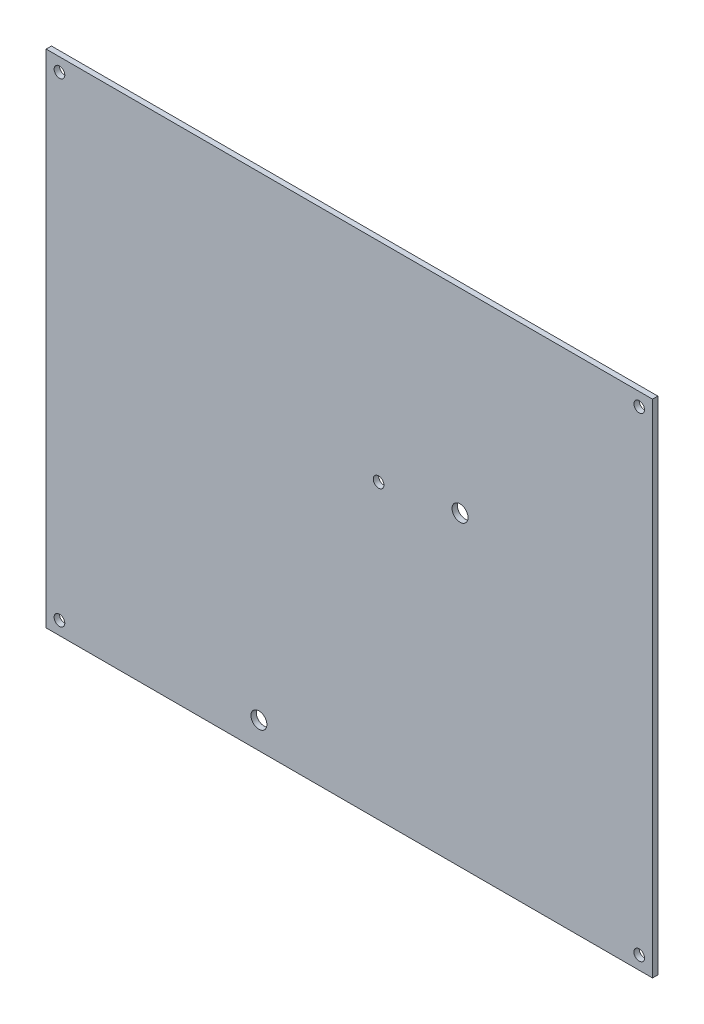
from build123d import *

# Parameters (mm, degrees)
SKETCH1_W           = 114
SKETCH1_H           = 110
BOSS_EXTRUDE1_DEPTH = 1
SKETCH2_R           = 1
CUT_EXTRUDE1_DEPTH  = 2
SKETCH3_R           = 1
CUT_EXTRUDE2_DEPTH  = 10
SKETCH4_W           = 15.73492188
SKETCH4_H           = 20.720243664
BOSS_EXTRUDE2_DEPTH = 1
SKETCH6_R           = 1
CUT_EXTRUDE3_DEPTH  = 10
SKETCH7_R           = 1.5
CUT_EXTRUDE4_DEPTH  = 10
SKETCH8_R           = 1.5
CUT_EXTRUDE5_DEPTH  = 10
SKETCH9_R           = 1
CUT_EXTRUDE6_DEPTH  = 2
SKETCH10_R          = 1
CUT_EXTRUDE7_DEPTH  = 2
SKETCH11_W          = 114
SKETCH11_H          = 15.75
CUT_EXTRUDE8_DEPTH  = 2


with BuildPart() as part:
    # Sketch1 → Boss-Extrude1 (new body)
    with BuildSketch(Plane.XY):
        with Locations((-26.754516262, 8.399305556)):
            Rectangle(SKETCH1_W, SKETCH1_H)
    extrude(amount=BOSS_EXTRUDE1_DEPTH)

    # Sketch2 → Cut-Extrude1 (cut, through all)
    with BuildSketch(Plane.XY.offset(1)):
        with Locations((-81.254516262, 60.899305556)):
            Circle(SKETCH2_R)
        with Locations((27.745483738, 60.899305556)):
            Circle(SKETCH2_R)
        with Locations((27.745483738, -44.100694444)):
            Circle(SKETCH2_R)
        with Locations((-81.254516262, -44.100694444)):
            Circle(SKETCH2_R)
    extrude(amount=-CUT_EXTRUDE1_DEPTH, mode=Mode.SUBTRACT)

    # Sketch3 → Cut-Extrude2 (cut)
    with BuildSketch(Plane(origin=(0, 0, 0), x_dir=(-1, 0, 0), z_dir=(0, 0, -1))):
        with Locations((28.754516262, 11.899305556)):
            Circle(SKETCH3_R)
    extrude(amount=-CUT_EXTRUDE2_DEPTH, mode=Mode.SUBTRACT)

    # Sketch4 → Boss-Extrude2 (add, through all)
    with BuildSketch(Plane.XY.offset(1)):
        with Locations((-27.299785832, 6.529809887)):
            Rectangle(SKETCH4_W, SKETCH4_H)
    extrude(amount=-BOSS_EXTRUDE2_DEPTH)

    # Sketch6 → Cut-Extrude3 (cut)
    with BuildSketch(Plane.XY.offset(1)):
        with Locations((-21.254516262, 8.399305556)):
            Circle(SKETCH6_R)
    extrude(amount=-CUT_EXTRUDE3_DEPTH, mode=Mode.SUBTRACT)

    # Sketch7 → Cut-Extrude4 (cut)
    with BuildSketch(Plane.XY.offset(1)):
        with Locations((-43.754516262, -41.600694444)):
            Circle(SKETCH7_R)
    extrude(amount=-CUT_EXTRUDE4_DEPTH, mode=Mode.SUBTRACT)

    # Sketch8 → Cut-Extrude5 (cut)
    with BuildSketch(Plane.XY.offset(1)):
        with Locations((-5.944516262, 11.009305556)):
            Circle(SKETCH8_R)
    extrude(amount=-CUT_EXTRUDE5_DEPTH, mode=Mode.SUBTRACT)

    # Sketch9 → Cut-Extrude6 (cut, through all)
    with BuildSketch(Plane.XY.offset(1)):
        with Locations((-81.254516262, 45.149305556)):
            Circle(SKETCH9_R)
    extrude(amount=-CUT_EXTRUDE6_DEPTH, mode=Mode.SUBTRACT)

    # Sketch10 → Cut-Extrude7 (cut, through all)
    with BuildSketch(Plane.XY.offset(1)):
        with Locations((27.745483738, 45.149305556)):
            Circle(SKETCH10_R)
    extrude(amount=-CUT_EXTRUDE7_DEPTH, mode=Mode.SUBTRACT)

    # Sketch11 → Cut-Extrude8 (cut, through all)
    with BuildSketch(Plane.XY.offset(1)):
        with Locations((-26.754516262, 55.524305556)):
            Rectangle(SKETCH11_W, SKETCH11_H)
    extrude(amount=-CUT_EXTRUDE8_DEPTH, mode=Mode.SUBTRACT)


solid = part.part
